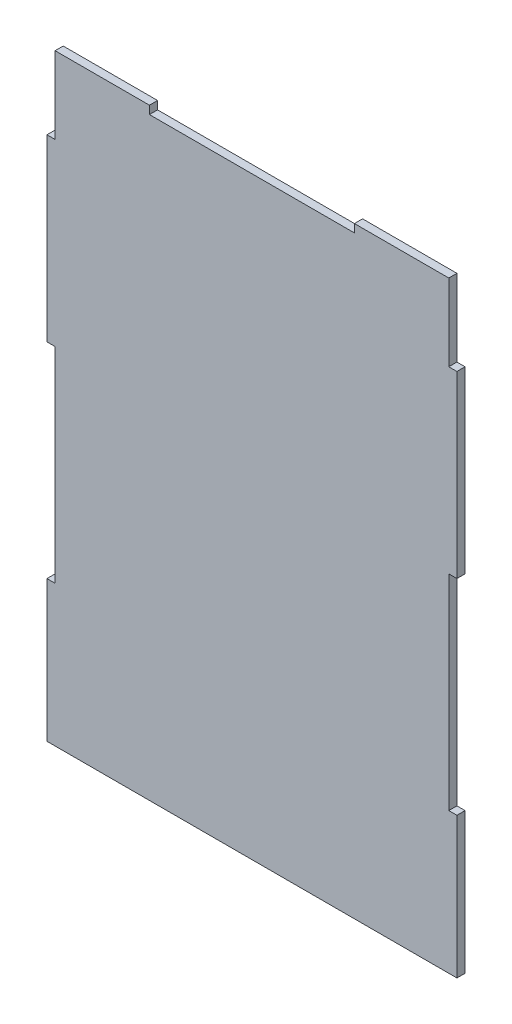
from build123d import *

# Parameters (mm, degrees)
BOSS_EXTRUDE1_DEPTH = 3.175


with BuildPart() as part:
    # Sketch1 → Boss-Extrude1 (new body)
    with BuildSketch(Plane.XY):
        Polygon((0, 0), (80, 0), (80, 55), (76.825, 55), (76.825, 135), (80, 135), (80, 205), (76.825, 205), (76.825, 235), (40, 235), (40, 231.825), (0, 231.825), (-40, 231.825), (-40, 235), (-76.825, 235), (-76.825, 205), (-80, 205), (-80, 135), (-76.825, 135), (-76.825, 55), (-80, 55), (-80, 0), align=None)
    extrude(amount=-BOSS_EXTRUDE1_DEPTH)


solid = part.part
